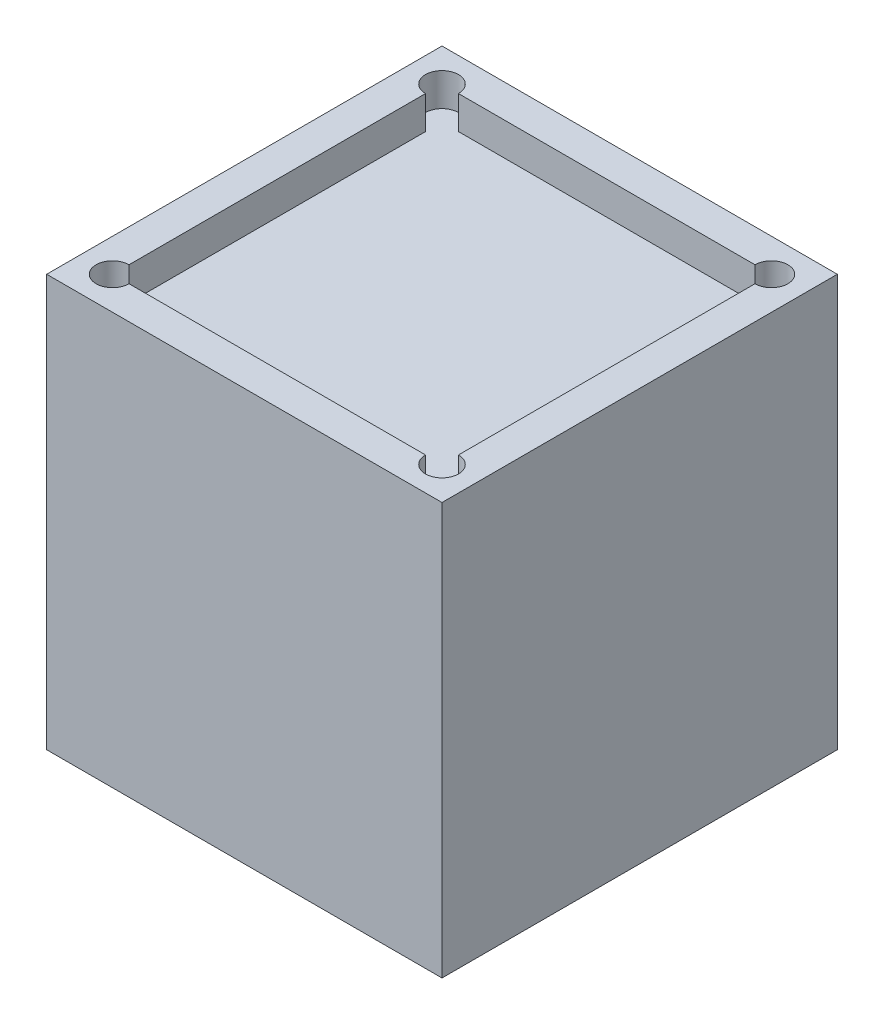
from build123d import *

# Parameters (mm, degrees)
SKETCH1_W                          = 12
SKETCH1_H                          = 12
BOSS_EXTRUDE1_DEPTH                = 11.5
SKETCH2_W                          = 12
SKETCH2_H                          = 12
SKETCH2_W_2                        = 10
SKETCH2_H_2                        = 10
BOSS_EXTRUDE2_DEPTH                = 1
F_1_0MM_DOWEL_HOLE1_D              = 1
F_1_0MM_DOWEL_HOLE1_DEPTH          = 1
F_1_16_0_0625_DIAMETER_HOLE1_D     = 1.5875
F_1_16_0_0625_DIAMETER_HOLE1_DEPTH = 7.5
M2X0_4_TAPPED_HOLE1_D              = 1.6
M2X0_4_TAPPED_HOLE1_DEPTH          = 5.2
M2X0_4_TAPPED_HOLE1_TIP            = 0.480688495


with BuildPart() as part:
    # Sketch1 → Boss-Extrude1 (new body)
    with BuildSketch(Plane(origin=(0, 0, 0), x_dir=(1, 0, 0), z_dir=(0, 1, 0))):
        Rectangle(SKETCH1_W, SKETCH1_H)
    extrude(amount=BOSS_EXTRUDE1_DEPTH)

    # Sketch2 → Boss-Extrude2 (add)
    with BuildSketch(Plane(origin=(0, 11.5, 0), x_dir=(1, 0, 0), z_dir=(0, 1, 0))):
        Rectangle(SKETCH2_W, SKETCH2_H)
        Rectangle(SKETCH2_W_2, SKETCH2_H_2, mode=Mode.SUBTRACT)
    extrude(amount=BOSS_EXTRUDE2_DEPTH)

    # Ø1.0mm Dowel Hole1
    with Locations(Plane(origin=(0, 12.5, 0), x_dir=(1, 0, 0), z_dir=(0, 1, 0))):
        with Locations((-5, 5), (5, 5), (5, -5), (-5, -5)):
            Hole(F_1_0MM_DOWEL_HOLE1_D / 2, depth=F_1_0MM_DOWEL_HOLE1_DEPTH)

    # 1/16 (0.0625) Diameter Hole1
    with Locations(Plane(origin=(0, 0, 0), x_dir=(-1, 0, 0), z_dir=(0, -1, 0))):
        with Locations((3.878679656, 3.878679656), (-3.878679656, -3.878679656)):
            Hole(F_1_16_0_0625_DIAMETER_HOLE1_D / 2, depth=F_1_16_0_0625_DIAMETER_HOLE1_DEPTH)

    # M2x0.4 Tapped Hole1
    with Locations(Plane(origin=(0, 0, 0), x_dir=(-1, 0, 0), z_dir=(0, -1, 0))):
        with Locations((3.878679656, -3.878679656), (-3.878679656, 3.878679656)):
            Hole(M2X0_4_TAPPED_HOLE1_D / 2, depth=M2X0_4_TAPPED_HOLE1_DEPTH)
            with Locations((0, 0, -(M2X0_4_TAPPED_HOLE1_DEPTH + M2X0_4_TAPPED_HOLE1_TIP / 2))):  # 118° drill point
                Cone(0, M2X0_4_TAPPED_HOLE1_D / 2, M2X0_4_TAPPED_HOLE1_TIP, mode=Mode.SUBTRACT)


solid = part.part
